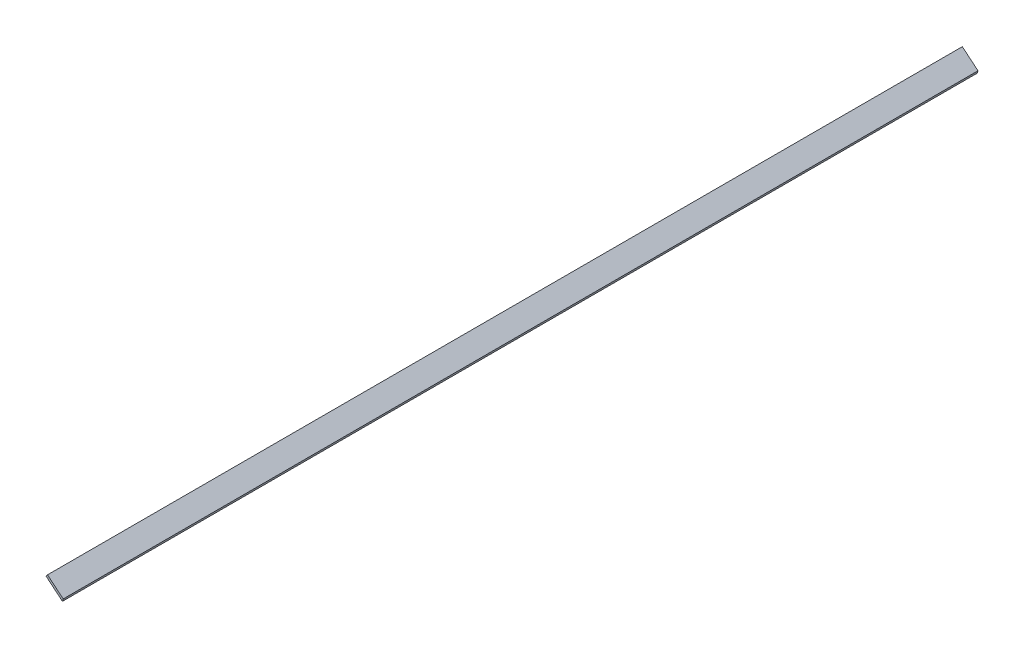
from build123d import *

# Parameters (mm, degrees)
BOSS_EXTRUDE1_DEPTH = 901.7


with BuildPart() as part:
    # Sketch1 → Boss-Extrude1 (new body)
    with BuildSketch(Plane.XY):
        Polygon((0, 0), (0.760500689, 2.441106772), (-14.68385363, 15.310622307), (-16.196043147, 13.495884942), align=None)
    extrude(amount=BOSS_EXTRUDE1_DEPTH)


solid = part.part
